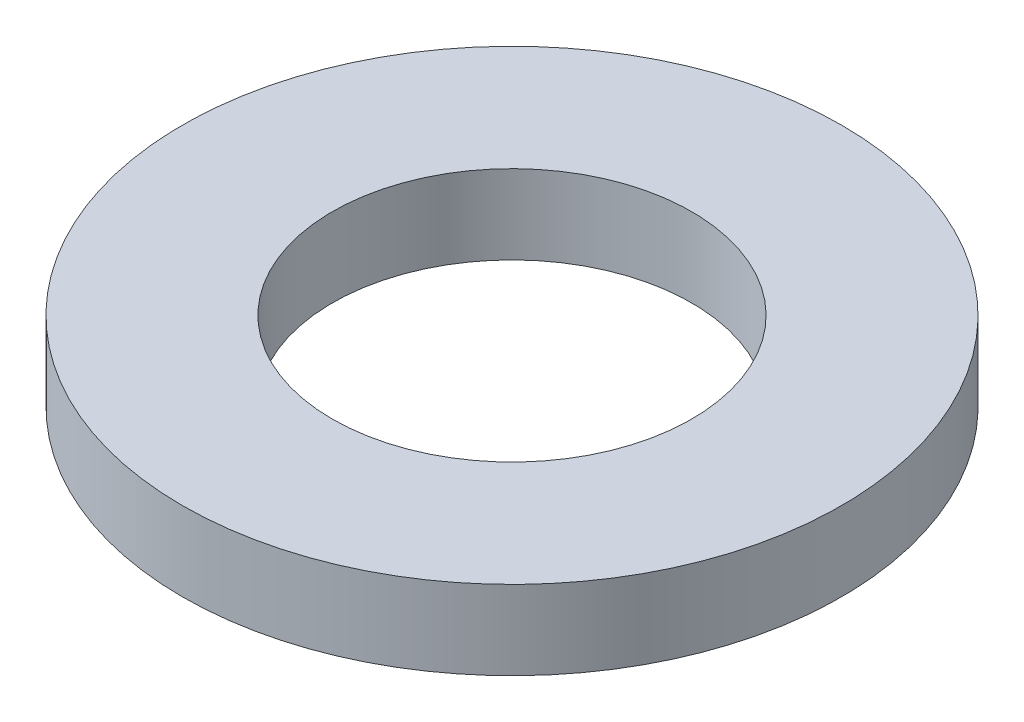
from build123d import *

# Parameters (mm, degrees)
SKETCH1_R           = 11.6459
SKETCH1_R_2         = 6.35
BOSS_EXTRUDE1_DEPTH = 1.397


with BuildPart() as part:
    # Sketch1 → Boss-Extrude1 (new body, symmetric)
    with BuildSketch(Plane(origin=(0, 0, 0), x_dir=(1, 0, 0), z_dir=(0, 1, 0))):
        Circle(SKETCH1_R)
        Circle(SKETCH1_R_2, mode=Mode.SUBTRACT)
    extrude(amount=BOSS_EXTRUDE1_DEPTH, both=True)


solid = part.part
